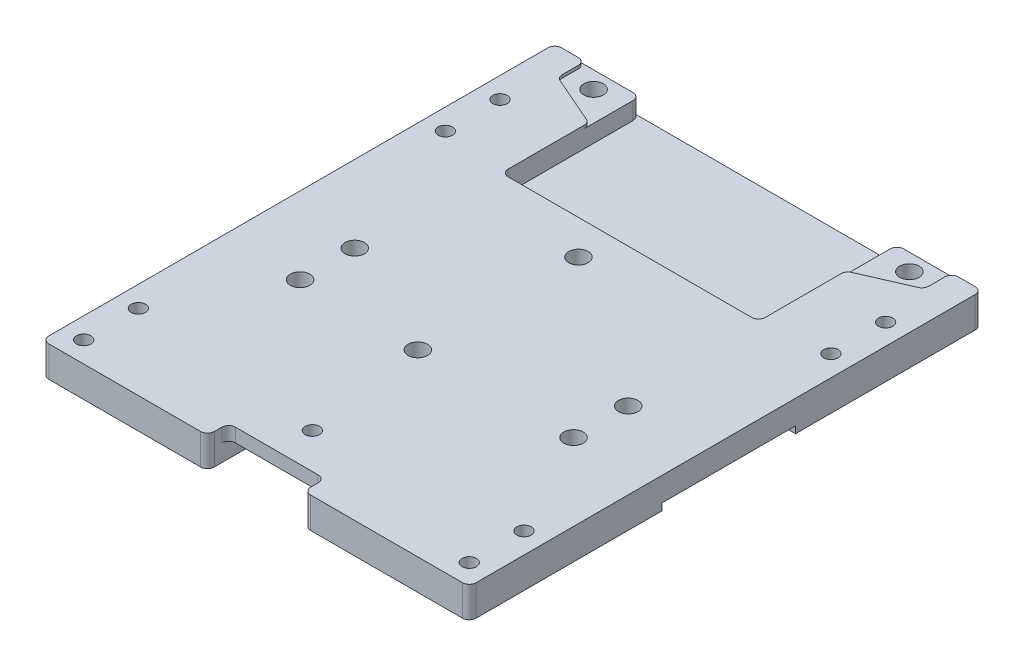
from build123d import *

# Parameters (mm, degrees)
SKETCH1_R           = 2.1
SKETCH1_R_2         = 2.85
BOSS_EXTRUDE1_DEPTH = 9
CUT_EXTRUDE1_DEPTH  = 4
SKETCH10_W          = 28.2
SKETCH10_H          = 42
CUT_EXTRUDE8_DEPTH  = 5
SKETCH11_R          = 2.1
CUT_EXTRUDE9_DEPTH  = 5
CUT_EXTRUDE2_DEPTH  = 2
SKETCH5_R           = 2.85
CUT_EXTRUDE3_DEPTH  = 8
SKETCH7_W           = 75.2
SKETCH7_H           = 40.5
CUT_EXTRUDE5_DEPTH  = 6
SKETCH12_R          = 2.85
CUT_EXTRUDE10_DEPTH = 10
CUT_EXTRUDE11_DEPTH = 0.9
FILLET1_R           = 2
FILLET2_R           = 2
FILLET3_R           = 2


with BuildPart() as part:
    # Sketch1 → Boss-Extrude1 (new body)
    with BuildSketch(Plane(origin=(0, 0, 0), x_dir=(1, 0, 0), z_dir=(0, 1, 0))):
        Polygon((76.6, 0), (125, 0), (125, 150), (0, 150), (0, 0), (48.4, 0), (48.4, -15), (76.6, -15), align=None)
        with Locations((6.1, 127.9)):
            Circle(SKETCH1_R, mode=Mode.SUBTRACT)
        with Locations((6.1, 111.9)):
            Circle(SKETCH1_R, mode=Mode.SUBTRACT)
        with Locations((118.9, 127.9)):
            Circle(SKETCH1_R, mode=Mode.SUBTRACT)
        with Locations((118.9, 111.9)):
            Circle(SKETCH1_R, mode=Mode.SUBTRACT)
        with Locations((118.9, 22.1)):
            Circle(SKETCH1_R, mode=Mode.SUBTRACT)
        with Locations((118.9, 6.1)):
            Circle(SKETCH1_R, mode=Mode.SUBTRACT)
        with Locations((6.1, 6.1)):
            Circle(SKETCH1_R, mode=Mode.SUBTRACT)
        with Locations((6.1, 22.1)):
            Circle(SKETCH1_R, mode=Mode.SUBTRACT)
        with Locations((54.5, -8.9)):
            Circle(SKETCH1_R, mode=Mode.SUBTRACT)
        with Locations((70.5, -8.9)):
            Circle(SKETCH1_R, mode=Mode.SUBTRACT)
        with Locations((62.5, -0.9)):
            Circle(SKETCH1_R, mode=Mode.SUBTRACT)
        with Locations((102.5, 53)):
            Circle(SKETCH1_R_2, mode=Mode.SUBTRACT)
        with Locations((22.5, 69)):
            Circle(SKETCH1_R_2, mode=Mode.SUBTRACT)
        with Locations((102.5, 69)):
            Circle(SKETCH1_R_2, mode=Mode.SUBTRACT)
        with Locations((22.5, 53)):
            Circle(SKETCH1_R_2, mode=Mode.SUBTRACT)
    extrude(amount=BOSS_EXTRUDE1_DEPTH)

    # Sketch2 → Cut-Extrude1 (cut)
    with BuildSketch(Plane(origin=(0, 9, 0), x_dir=(1, 0, 0), z_dir=(0, 1, 0))):
        Polygon((76.6, -15), (76.6, 0), (76.6, 6.2), (48.4, 6.2), (48.4, 0), (48.4, -15), align=None)
    extrude(amount=-CUT_EXTRUDE1_DEPTH, mode=Mode.SUBTRACT)

    # Sketch10 → Cut-Extrude8 (cut)
    with BuildSketch(Plane(origin=(0, 0, 0), x_dir=(1, 0, 0), z_dir=(0, 1, 0))):
        with Locations((62.5, 6)):
            Rectangle(SKETCH10_W, SKETCH10_H)
    extrude(amount=CUT_EXTRUDE8_DEPTH, mode=Mode.SUBTRACT)

    # Sketch11 → Cut-Extrude9 (cut, through all)
    with BuildSketch(Plane.XZ.offset(-5)):
        with Locations((62.5, -16.6)):
            Circle(SKETCH11_R)
    extrude(amount=-CUT_EXTRUDE9_DEPTH, mode=Mode.SUBTRACT)

    # Sketch3 → Cut-Extrude2 (cut)
    with BuildSketch(Plane.XZ):
        Polygon((0, -56.45), (27, -56.45), (27, -46.45), (86.5, -46.45), (86.5, -56.45), (125, -56.45), (125, -95.45), (86.5, -95.45), (86.5, -105.45), (27, -105.45), (27, -95.45), (0, -95.45), align=None)
    extrude(amount=-CUT_EXTRUDE2_DEPTH, mode=Mode.SUBTRACT)

    # Sketch5 → Cut-Extrude3 (cut, through all)
    with BuildSketch(Plane.XZ.offset(-2)):
        with Locations((57.5, -52.45)):
            Circle(SKETCH5_R)
        with Locations((57.5, -99.45)):
            Circle(SKETCH5_R)
    extrude(amount=-CUT_EXTRUDE3_DEPTH, mode=Mode.SUBTRACT)

    # Sketch7 → Cut-Extrude5 (cut)
    with BuildSketch(Plane(origin=(0, 9, 0), x_dir=(1, 0, 0), z_dir=(0, 1, 0))):
        with Locations((62.5, 129.75)):
            Rectangle(SKETCH7_W, SKETCH7_H)
    extrude(amount=-CUT_EXTRUDE5_DEPTH, mode=Mode.SUBTRACT)

    # Sketch12 → Cut-Extrude10 (cut, through all)
    with BuildSketch(Plane(origin=(0, 9, 0), x_dir=(1, 0, 0), z_dir=(0, 1, 0))):
        with Locations((16.3, 145.05)):
            Circle(SKETCH12_R)
        with Locations((108.7, 145.05)):
            Circle(SKETCH12_R)
    extrude(amount=-CUT_EXTRUDE10_DEPTH, mode=Mode.SUBTRACT)

    # Sketch13 → Cut-Extrude11 (cut)
    with BuildSketch(Plane(origin=(0, 9, 0), x_dir=(1, 0, 0), z_dir=(0, 1, 0))):
        Polygon((24.9, 135), (8.9, 142), (8.9, 150), (24.9, 150), align=None)
        Polygon((100.1, 150), (100.1, 135), (116.1, 142), (116.1, 150), align=None)
    extrude(amount=-CUT_EXTRUDE11_DEPTH, mode=Mode.SUBTRACT)

    # Fillet1
    fillet1_edges = [part.edges().sort_by_distance(p)[0] for p in [
        (0, 4.5, -150),
        (125, 4.5, -150),
        (125, 4.5, 0),
        (0, 4.5, 0),
        (76.6, 7, -6.2),
        (48.4, 7, -6.2),
    ]]
    fillet(fillet1_edges, radius=FILLET1_R)

    # Fillet2
    fillet2_edges = [part.edges().sort_by_distance(p)[0] for p in [
        (76.6, 4.5, 0),
        (48.4, 4.5, 0),
    ]]
    fillet(fillet2_edges, radius=FILLET2_R)

    # Fillet3
    fillet3_edges = [part.edges().sort_by_distance(p)[0] for p in [
        (24.9, 6, -109.5),
        (24.9, 5.55, -150),
        (100.1, 5.55, -150),
        (100.1, 6, -109.5),
        (8.9, 8.55, -150),
        (8.9, 8.55, -142),
        (24.9, 8.55, -135),
        (100.1, 8.55, -135),
        (116.1, 8.55, -142),
        (116.1, 8.55, -150),
    ]]
    fillet(fillet3_edges, radius=FILLET3_R)


solid = part.part
